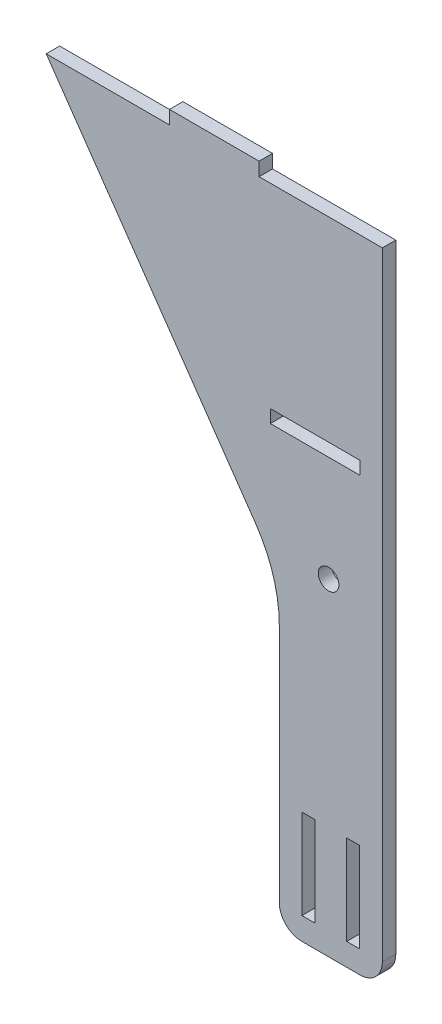
from build123d import *

# Parameters (mm, degrees)
SKETCH1_W           = 2.9
SKETCH1_H           = 20
BOSS_EXTRUDE1_DEPTH = 3
FILLET1_R           = 5
FILLET2_R           = 30
SKETCH4_R           = 2.3
CUT_EXTRUDE1_DEPTH  = 10
SKETCH5_W           = 20
SKETCH5_H           = 2.9
CUT_EXTRUDE2_DEPTH  = 4


with BuildPart() as part:
    # Sketch1 → Boss-Extrude1 (new body)
    with BuildSketch(Plane.XY):
        Polygon((0, 0), (-23, 0), (-23, 68), (-75, 143), (-47.5, 143), (-47.5, 146), (-27.5, 146), (-27.5, 143), (0, 143), align=None)
        with Locations((-16.5, 15)):
            Rectangle(SKETCH1_W, SKETCH1_H, mode=Mode.SUBTRACT)
        with Locations((-6.5, 15)):
            Rectangle(SKETCH1_W, SKETCH1_H, mode=Mode.SUBTRACT)
    extrude(amount=BOSS_EXTRUDE1_DEPTH)

    # Fillet1
    fillet1_edges = [part.edges().sort_by_distance(p)[0] for p in [
        (0, 0, 1.5),
        (-23, 0, 1.5),
    ]]
    fillet(fillet1_edges, radius=FILLET1_R)

    # Fillet2
    fillet2_edges = [part.edges().sort_by_distance(p)[0] for p in [
        (-23, 68, 1.5),
    ]]
    fillet(fillet2_edges, radius=FILLET2_R)

    # Sketch4 → Cut-Extrude1 (cut)
    with BuildSketch(Plane.XY.offset(3)):
        with Locations((-12, 73)):
            Circle(SKETCH4_R)
    extrude(amount=-CUT_EXTRUDE1_DEPTH, mode=Mode.SUBTRACT)

    # Sketch5 → Cut-Extrude2 (cut, through all)
    with BuildSketch(Plane(origin=(0, 0, 0), x_dir=(-1, 0, 0), z_dir=(0, 0, -1))):
        with Locations((15, 98)):
            Rectangle(SKETCH5_W, SKETCH5_H)
    extrude(amount=-CUT_EXTRUDE2_DEPTH, mode=Mode.SUBTRACT)


solid = part.part
